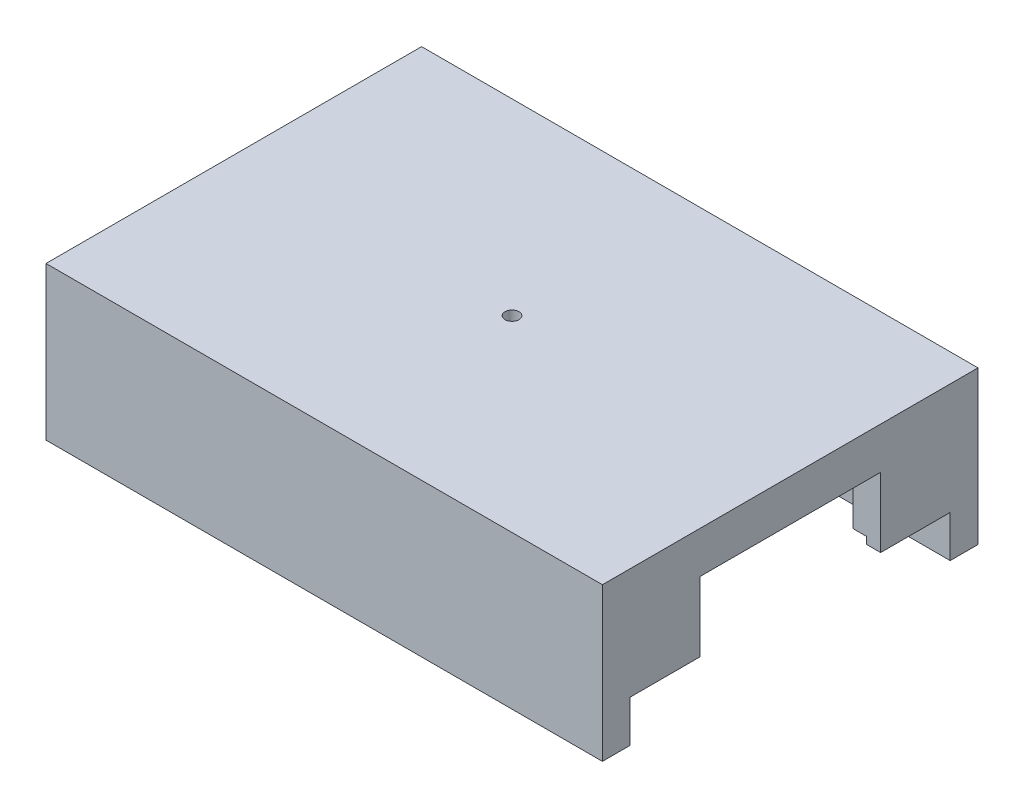
from build123d import *

# Parameters (mm, degrees)
SKETCH3_W           = 40
SKETCH3_H           = 40
SKETCH3_R           = 5
SKETCH3_R_2         = 0.5
BOSS_EXTRUDE2_DEPTH = 3
BOSS_EXTRUDE3_DEPTH = 8
SKETCH6_W           = 2
SKETCH6_H           = 5
BOSS_EXTRUDE5_DEPTH = 5
SKETCH7_W           = 40
SKETCH7_H           = 6.5
CUT_EXTRUDE1_DEPTH  = 3
SKETCH8_W           = 40
SKETCH8_H           = 6.5
CUT_EXTRUDE2_DEPTH  = 3
CUT_EXTRUDE3_START  = -1
SKETCH5_W           = 5
SKETCH5_H           = 0.5
CUT_EXTRUDE3_DEPTH  = 6


with BuildPart() as part:
    # Sketch3 → Boss-Extrude2 (new body)
    with BuildSketch(Plane(origin=(0, 0, 0), x_dir=(1, 0, 0), z_dir=(0, 1, 0))):
        Rectangle(SKETCH3_W, SKETCH3_H)
        Circle(SKETCH3_R, mode=Mode.SUBTRACT)
        Circle(SKETCH3_R)
        Circle(SKETCH3_R_2, mode=Mode.SUBTRACT)
    extrude(amount=-BOSS_EXTRUDE2_DEPTH)

    # Sketch4 → Boss-Extrude3 (add)
    with BuildSketch(Plane.XZ.offset(3)):
        Polygon((20, -11.5), (0, -11.5), (-20, -11.5), (-20, -13.5), (20, -13.5), align=None)
        Polygon((-20, 11.5), (0, 11.5), (20, 11.5), (20, 13.5), (-20, 13.5), align=None)
    extrude(amount=BOSS_EXTRUDE3_DEPTH)

    # Sketch6 → Boss-Extrude5 (add)
    with BuildSketch(Plane.XZ.offset(3)):
        with Locations((19, 9)):
            Rectangle(SKETCH6_W, SKETCH6_H)
        with Locations((19, -9)):
            Rectangle(SKETCH6_W, SKETCH6_H)
        with Locations((-19, -9)):
            Rectangle(SKETCH6_W, SKETCH6_H)
        with Locations((-19, 9)):
            Rectangle(SKETCH6_W, SKETCH6_H)
    extrude(amount=BOSS_EXTRUDE5_DEPTH)

    # Sketch7 → Cut-Extrude1 (cut)
    with BuildSketch(Plane(origin=(0, -3, 0), x_dir=(-1, 0, 0), z_dir=(0, -1, 0))):
        with Locations((0, -16.75)):
            Rectangle(SKETCH7_W, SKETCH7_H)
    extrude(amount=-CUT_EXTRUDE1_DEPTH, mode=Mode.SUBTRACT)

    # Sketch8 → Cut-Extrude2 (cut)
    with BuildSketch(Plane.XZ.offset(3)):
        with Locations((0, -16.75)):
            Rectangle(SKETCH8_W, SKETCH8_H)
    extrude(amount=-CUT_EXTRUDE2_DEPTH, mode=Mode.SUBTRACT)

    # Sketch5 → Cut-Extrude3 (cut)
    with BuildSketch(Plane.XY.offset(-11.5).offset(CUT_EXTRUDE3_START)):
        Polygon((19, -7.5), (0, -7.5), (0, -8), (5, -8), (5, -8.5), (19, -8.5), align=None)
        Polygon((0, -8), (0, -7.5), (-19, -7.5), (-19, -8.5), (-5, -8.5), (-5, -8), align=None)
        with Locations((-2.5, -8.25)):
            Rectangle(SKETCH5_W, SKETCH5_H)
        with Locations((2.5, -8.25)):
            Rectangle(SKETCH5_W, SKETCH5_H)
    cut_extrude3 = extrude(amount=CUT_EXTRUDE3_DEPTH, mode=Mode.SUBTRACT)

    # Mirror2: Cut-Extrude3 across plane
    add(cut_extrude3.mirror(Plane.XY), mode=Mode.SUBTRACT)


solid = part.part
